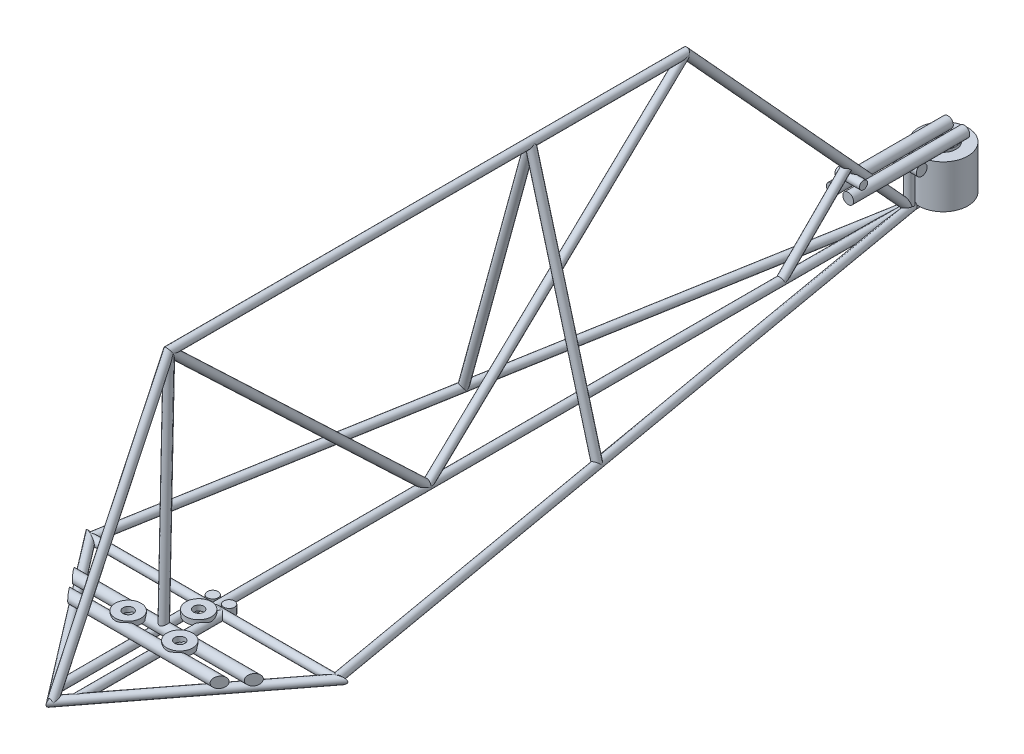
from build123d import *

# Parameters (mm, degrees)
MOTOR_MOUTING_WASHERS_DEPTH        = 1
MOTOR_MOUTING_WASHERS_DEPTH_BACK   = 1
SKETCH1_R                          = 5.000000000000007
SKETCH1_R_2                        = 1.9843750000000187
MOTOR_MOUTING_WASHERS_2_DEPTH      = 1
MOTOR_MOUTING_WASHERS_2_DEPTH_BACK = 1
SKETCH1_R_3                        = 1.9843750000000173
MOTOR_MOUNTING_WASHER_2_DEPTH      = 1
MOTOR_MOUNTING_WASHER_2_DEPTH_BACK = 1
SKETCH37_R                         = 5.000000000000008
SKETCH37_R_2                       = 1.9843750000000226
SKETCH20_R                         = 1.587499999999985
MOTOR_MOUNT_2_DEPTH                = 40
MOTOR_MOUNT_2_DEPTH_BACK           = 40
SKETCH21_R                         = 2.087499999999984
TRIMING_MOUNTS_DEPTH               = 205.0959713088859
MOTOR_MOUNT_3_REACH                = 84.34
MOTOR_MOUNT_3_END_RADIUS           = 1.587499999999985
SKETCH34_R                         = 1.5874999999999997
MOTOR_MOUNT_3_2_REACH              = 84.34
MOTOR_MOUNT_3_2_END_RADIUS         = 1.587499999999985
SKETCH36_R                         = 1.5875000000000006
SKETCH7_R                          = 1.5874999999999995
CONSTRAINT_FEATURE_REACH           = 312.3
CONSTRAINT_FEATURE_END_RADIUS      = 2.087499999999984
SKETCH43_R                         = 1.5875
CRITICAL_JOINT_SUPPORT_DEPTH       = 1.5875
CRITICAL_JOINT_SUPPORT_DEPTH_BACK  = 1.5875
SKETCH38_R                         = 2.0875
SKETCH27_R                         = 1.5875
DIAGONAL_1_REACH                   = 312.3
DIAGONAL_1_END_RADIUS              = 1.5874999999999995
SKETCH22_R                         = 1.5874999999999988
DIAGONAL_2_REACH                   = 272.577
DIAGONAL_2_END_RADIUS              = 1.5874999999999995
SKETCH24_R                         = 1.5875000000000004
SKETCH11_R                         = 9.524999999999999
ELECTRO_MAGNET_DEPTH               = 16.764000000000003
SKETCH12_R                         = 5.000000000000004
SKETCH12_R_2                       = 1.9843750000000118
MAGET_WASHER_DEPTH                 = 1
SKETCH15_R                         = 2.0874999999999995
SKETCH15_R_2                       = 2.0875
SKETCH17_R                         = 1.5874999999999997
WASHER_MOUNT_3_DEPTH               = 4.7625
WASHER_MOUNT_3_DEPTH_BACK          = 4.7625
SKETCH18_R                         = 1.5874999999999995
SKETCH18_R_2                       = 2.087499999999984


with BuildPart() as part:
    # Sketch1 → Motor mouting washers (new, two sides: drawn at the far end of the back side and taken through both)
    with BuildSketch(Plane(origin=(0, 4.7625, 0), x_dir=(1, 0, 0), z_dir=(0, 1, 0)).offset(-MOTOR_MOUTING_WASHERS_DEPTH_BACK)):
        with Locations(Location((9.999999999999954, -155.7735026918963, 0), (0, 0, 270))):
            Circle(SKETCH1_R)
        with Locations(Location((9.999999999999954, -155.7735026918963, 0), (0, 0, 270))):
            Circle(SKETCH1_R_2, mode=Mode.SUBTRACT)
    extrude(amount=MOTOR_MOUTING_WASHERS_DEPTH + MOTOR_MOUTING_WASHERS_DEPTH_BACK)



with BuildPart() as body_2:
    # Sketch1 → Motor mouting washers 2 (new, two sides: drawn at the far end of the back side and taken through both)
    with BuildSketch(Plane(origin=(0, 4.7625, 0), x_dir=(1, 0, 0), z_dir=(0, 1, 0)).offset(-MOTOR_MOUTING_WASHERS_2_DEPTH_BACK)):
        with Locations(Location((-10.00000000000005, -155.77350269189623, 0), (0, 0, 270))):
            Circle(SKETCH1_R)
        with Locations(Location((-10.00000000000005, -155.77350269189623, 0), (0, 0, 270))):
            Circle(SKETCH1_R_3, mode=Mode.SUBTRACT)
    extrude(amount=MOTOR_MOUTING_WASHERS_2_DEPTH + MOTOR_MOUTING_WASHERS_2_DEPTH_BACK)


with BuildPart() as body_3:
    # Sketch37 → Motor mounting washer 2 (new, two sides: drawn at the far end of the back side and taken through both)
    with BuildSketch(Plane(origin=(0, 1.5875, 0), x_dir=(-1, 0, 0), z_dir=(0, 1, 0)).offset(-MOTOR_MOUNTING_WASHER_2_DEPTH_BACK)):
        with Locations(Location((-3.556e-14, 138.45299461620746, 0), (0, 0, 90))):
            Circle(SKETCH37_R)
        with Locations(Location((-3.556e-14, 138.45299461620746, 0), (0, 0, 90))):
            Circle(SKETCH37_R_2, mode=Mode.SUBTRACT)
    extrude(amount=MOTOR_MOUNTING_WASHER_2_DEPTH + MOTOR_MOUNTING_WASHER_2_DEPTH_BACK)


with BuildPart() as body_4:
    # Moter Mount 1: sweep along a path in Sketch19
    with BuildLine(Plane(origin=(0, 0, 0), x_dir=(1, 0, 0), z_dir=(0, 1, 0))) as moter_mount_1_path:
        Line((-47.499999999999986, -133), (47.500000000000014, -133))
        Line((47.500000000000014, -133), (2.388e-14, -195))
        Line((2.388e-14, -195), (-47.499999999999986, -133))
    # Sketch20 → Moter Mount 1 (sweep)
    with BuildSketch(Plane(origin=(0, 0, 0), x_dir=(0, 0, -1), z_dir=(1, 0, 0))):
        with Locations((-133, 0)):
            Circle(SKETCH20_R)
    sweep(path=moter_mount_1_path.line, transition=Transition.RIGHT)


with BuildPart() as part_1:
    add(part.part)

    add(body_2.part)  # Motor Mount 2 merges body 2

    add(body_4.part)  # Motor Mount 2 merges body 4
    # Sketch21 → Motor Mount 2 (add, two sides: drawn at the far end of the back side and taken through both)
    with BuildSketch(Plane(origin=(0, 0, 0), x_dir=(0, 0, -1), z_dir=(1, 0, 0)).offset(-MOTOR_MOUNT_2_DEPTH_BACK)):
        with Locations((-159.5235026918963, 3.1749999999999847)):
            Circle(SKETCH21_R)
        with Locations((-152.02350269189628, 3.1749999999999847)):
            Circle(SKETCH21_R)
    extrude(amount=MOTOR_MOUNT_2_DEPTH + MOTOR_MOUNT_2_DEPTH_BACK)

    # Sketch40 → Triming mounts (cut, through all)
    with BuildSketch(Plane(origin=(0, 0, 0), x_dir=(1, 0, 0), z_dir=(0, 1, 0))):
        Polygon((-40.09077542461257, -145.2813090102072), (-27.178648820588556, -162.13503215651224), (-40.11758580887597, -172.04792742979694), (-53.029712412899976, -155.1942042834919), align=None)
        Polygon((27.17864882058858, -162.13503215651224), (40.090775424612595, -145.2813090102072), (53.0297124129, -155.1942042834919), (40.11758580887599, -172.04792742979694), align=None)
    extrude(amount=TRIMING_MOUNTS_DEPTH, mode=Mode.SUBTRACT)

    # Motor Mount 3: up to this cylinder (the profile starts outside it)
    motor_mount_3_end = Plane(origin=(-31.318542272857652, 0, 154.12106061226999), z_dir=(0.6081627174581739, 0, 0.7938123891033004)) * Cylinder(MOTOR_MOUNT_3_END_RADIUS, 172.855, mode=Mode.PRIVATE)
    # Sketch34 → Motor Mount 3 (add, up to the surface)
    with BuildSketch(Plane.XY.offset(133), mode=Mode.PRIVATE) as motor_mount_3_sk1:
        with Locations(Location((-3.75, 0, 0), (0, 0, 90))):
            Circle(SKETCH34_R)
    motor_mount_3_tool1 = extrude(motor_mount_3_sk1.sketch, amount=MOTOR_MOUNT_3_REACH, mode=Mode.PRIVATE) - motor_mount_3_end
    add(motor_mount_3_tool1.solids().sort_by_distance((-3.75, 0, 133))[0])

    # Motor Mount 3 - 2: up to this cylinder (the profile starts outside it)
    motor_mount_3_2_end = Plane(origin=(31.31854227285769, 0, 154.12106061226999), z_dir=(0.6081627174581737, 0, -0.7938123891033005)) * Cylinder(MOTOR_MOUNT_3_2_END_RADIUS, 172.855, mode=Mode.PRIVATE)
    # Sketch36 → Motor Mount 3 - 2 (add, up to the surface)
    with BuildSketch(Plane.XY.offset(133), mode=Mode.PRIVATE) as motor_mount_3_2_sk1:
        with Locations(Location((3.75, 0, 0), (0, 0, 90))):
            Circle(SKETCH36_R)
    motor_mount_3_2_tool1 = extrude(motor_mount_3_2_sk1.sketch, amount=MOTOR_MOUNT_3_2_REACH, mode=Mode.PRIVATE) - motor_mount_3_2_end
    add(motor_mount_3_2_tool1.solids().sort_by_distance((3.75, 0, 133))[0])


    add(body_3.part)  # Main outline merges body 3
    # Main outline: sweep along a path in Sketch2
    with BuildLine(Plane(origin=(0, 0, 0), x_dir=(0, 0, -1), z_dir=(1, 0, 0))) as main_outline_path:
        Line((-133, 0), (136.8875, 0))
        Line((136.8875, 0), (49.999999999999986, 95))
        Line((49.999999999999986, 95), (-150.00000000000003, 94.99999999999997))
        Line((-150.00000000000003, 94.99999999999997), (-195, 0))
    # Sketch7 → Main outline (sweep)
    with BuildSketch(Plane.XY.offset(133)):
        Circle(SKETCH7_R)
    sweep(path=main_outline_path.line, transition=Transition.RIGHT)

    # Constraint feature: up to this cylinder (the profile starts outside it)
    constraint_feature_end = Plane(origin=(0, 3.1749999999999847, 152.02350269189628), z_dir=(1, 0, 0)) * Cylinder(CONSTRAINT_FEATURE_END_RADIUS, 629.775, mode=Mode.PRIVATE)
    # Sketch43 → Constraint feature (add, up to the surface)
    with BuildSketch(Plane(origin=(0, 95, 150.00000000000006), x_dir=(1, 0, 0), z_dir=(0, -0.9997572844696864, 0.022031163151291246)), mode=Mode.PRIVATE) as constraint_feature_sk1:
        with Locations(Location((0, 0, 0), (0, 0, 90))):
            Circle(SKETCH43_R)
    constraint_feature_tool1 = extrude(constraint_feature_sk1.sketch, amount=CONSTRAINT_FEATURE_REACH, mode=Mode.PRIVATE) - constraint_feature_end
    add(constraint_feature_tool1.solids().sort_by_distance((0, 95, 150))[0])

    # Sketch38 → Critical Joint Support (add, two sides: drawn at the far end of the back side and taken through both)
    with BuildSketch(Plane(origin=(0, 0, 0), x_dir=(1, 0, 0), z_dir=(0, 1, 0)).offset(-CRITICAL_JOINT_SUPPORT_DEPTH_BACK)):
        with Locations(Location((3.1750000000000003, -129.82500000000002, 0), (0, 0, 270))):
            Circle(SKETCH38_R)
        with Locations(Location((-3.1749999999999994, -129.82500000000002, 0), (0, 0, 270))):
            Circle(SKETCH38_R)
    extrude(amount=CRITICAL_JOINT_SUPPORT_DEPTH + CRITICAL_JOINT_SUPPORT_DEPTH_BACK)

    # Horizontal 1: sweep along a path in Sketch26
    with BuildLine(Plane(origin=(0, 0, 0), x_dir=(1, 0, 0), z_dir=(0, 1, 0))) as horizontal_1_path:
        Line((47.500000000000014, -133), (0, 138.0821842859154))
    # Sketch27 → Horizontal 1 (sweep)
    with BuildSketch(Plane(origin=(47.50000000000003, 0, 133), x_dir=(-0.9849930441637955, 0, 0.17259404088478575), z_dir=(-0.17259404088478575, 0, -0.9849930441637956))):
        Circle(SKETCH27_R)
    horizontal_1 = sweep(path=horizontal_1_path.line)

    # Opisite Horizontal: Horizontal 1 across plane
    add(horizontal_1.mirror(Plane(origin=(0, 0, 0), x_dir=(0, 0, 1), z_dir=(1, 0, 0))))

    # Diagonal 1: up to this cylinder (the profile starts outside it)
    diagonal_1_end = Plane(origin=(0, 0, 150), z_dir=(0, 0, 1)) * Cylinder(DIAGONAL_1_END_RADIUS, 628.775, mode=Mode.PRIVATE)
    # Sketch22 → Diagonal 1 (add, up to the surface)
    with BuildSketch(Plane(origin=(0, 94.99999999999999, 150.00000000000006), x_dir=(1, 0, 0), z_dir=(0, 0.6887494619146929, 0.724999433594414)), mode=Mode.PRIVATE) as diagonal_1_sk1:
        with Locations(Location((0, 0, 0), (0, 0, 180))):
            Circle(SKETCH22_R)
    diagonal_1_tool1 = extrude(diagonal_1_sk1.sketch, amount=-DIAGONAL_1_REACH, mode=Mode.PRIVATE) - diagonal_1_end
    add(diagonal_1_tool1.solids().sort_by_distance((0, 95, 150))[0])

    # Diagonal 2: up to this cylinder (the profile starts outside it)
    diagonal_2_end = Plane(origin=(0, 0, -50), z_dir=(0, 0, 1)) * Cylinder(DIAGONAL_2_END_RADIUS, 549.329, mode=Mode.PRIVATE)
    # Sketch24 → Diagonal 2 (add, up to the surface)
    with BuildSketch(Plane(origin=(0, 95, -49.999999999999986), x_dir=(1, 0, 0), z_dir=(0, -0.6887494619146931, 0.7249994335944138)), mode=Mode.PRIVATE) as diagonal_2_sk1:
        Circle(SKETCH24_R)
    diagonal_2_tool1 = extrude(diagonal_2_sk1.sketch, amount=DIAGONAL_2_REACH, mode=Mode.PRIVATE) - diagonal_2_end
    add(diagonal_2_tool1.solids().sort_by_distance((0, 95, -50))[0])

    # Sketch33 → Support (revolve)
    with BuildSketch(Plane.XY.offset(10), mode=Mode.PRIVATE) as support_sk:
        Polygon((0, 94.99999999999999), (25.94749548779716, 9.85e-15), (27.478900793534248, 0.41827507642739803), (1.531405305737075, 95.41827507642738), align=None)
    support = revolve(support_sk.sketch.rotate(Axis((0, 94.99999999999999, 10), (0.2634803631038635, -0.9646647595194179, 0)), 180), axis=Axis((0, 94.99999999999999, 10), (0.2634803631038635, -0.9646647595194179, 0)))

    # Second Support: Support across plane
    add(support.mirror(Plane(origin=(0, 0, 0), x_dir=(0, 0, 1), z_dir=(1, 0, 0))))

    # Sketch11 → Electro Magnet (add)
    with BuildSketch(Plane(origin=(0, -1.5875, 0), x_dir=(-1, 0, 0), z_dir=(0, 1, 0))):
        with Locations(Location((0, -150, 0), (0, 0, 90))):
            Circle(SKETCH11_R)
    extrude(amount=ELECTRO_MAGNET_DEPTH)

    # Sketch12 → Maget Washer (add)
    with BuildSketch(Plane(origin=(0, 15.1765, 0), x_dir=(1, 0, 0), z_dir=(0, 1, 0))):
        with Locations(Location((0, 150, 0), (0, 0, 270))):
            Circle(SKETCH12_R)
        with Locations(Location((0, 150, 0), (0, 0, 270))):
            Circle(SKETCH12_R_2, mode=Mode.SUBTRACT)
    extrude(amount=MAGET_WASHER_DEPTH)

    # Washer Mount 1: sweep along a path in Sketch14
    with BuildLine(Plane(origin=(0, 0, 0), x_dir=(0, 0, -1), z_dir=(1, 0, 0))) as washer_mount_1_path:
        Line((155, 17.764), (110, 17.763999999999992))
    # Sketch15 → Washer Mount 1 (sweep)
    with BuildSketch(Plane(origin=(0, 17.764, -155), x_dir=(1, 0, 0), z_dir=(0, 0, 1))):
        with Locations((3.1750000000000007, -1.42e-15)):
            Circle(SKETCH15_R)
        with Locations((-3.1750000000000007, -1.42e-15)):
            Circle(SKETCH15_R_2)
    sweep(path=washer_mount_1_path.line)

    # Washer Mount 2: sweep along a path in Sketch16
    with BuildLine(Plane(origin=(0, 0, 0), x_dir=(0, 0, -1), z_dir=(1, 0, 0))) as washer_mount_2_path:
        Line((136.8875, 0), (136.8875, 13.0015))
    # Sketch17 → Washer Mount 2 (sweep)
    with BuildSketch(Plane(origin=(0, 0, 0), x_dir=(1, 0, 0), z_dir=(0, 1, 0))):
        with Locations((0, 136.8875)):
            Circle(SKETCH17_R)
    sweep(path=washer_mount_2_path.line)

    # Sketch18 → Washer Mount 3 (add, two sides: drawn at the far end of the back side and taken through both)
    with BuildSketch(Plane(origin=(0, 0, 0), x_dir=(0, 0, -1), z_dir=(1, 0, 0)).offset(-WASHER_MOUNT_3_DEPTH_BACK)):
        with Locations((114.34764283068994, 20.872684344316944)):
            Circle(SKETCH18_R)
        with Locations(Location((136.8875, 14.588999999999999, 0), (0, 0, 60.644592022))):
            Circle(SKETCH18_R_2)
    extrude(amount=WASHER_MOUNT_3_DEPTH + WASHER_MOUNT_3_DEPTH_BACK)

    # Sketch39 → Front end brace (revolve)
    with BuildSketch(Plane(origin=(0, 0, 0), x_dir=(0, 0, -1), z_dir=(1, 0, 0)), mode=Mode.PRIVATE) as front_end_brace_sk:
        Polygon((88.3197990353684, -1.1225320151336564), (113.64494369414841, 24.202612643646088), (112.52241167901477, 25.325144658779738), (87.19726702023478, 0), align=None)
    revolve(front_end_brace_sk.sketch.rotate(Axis((0, 25.325144658779738, -112.52241167901477), (0, -0.7071067811865441, 0.707106781186551)), 165.155091633), axis=Axis((0, 25.325144658779738, -112.52241167901477), (0, -0.7071067811865441, 0.707106781186551)))


solid = part_1.part
